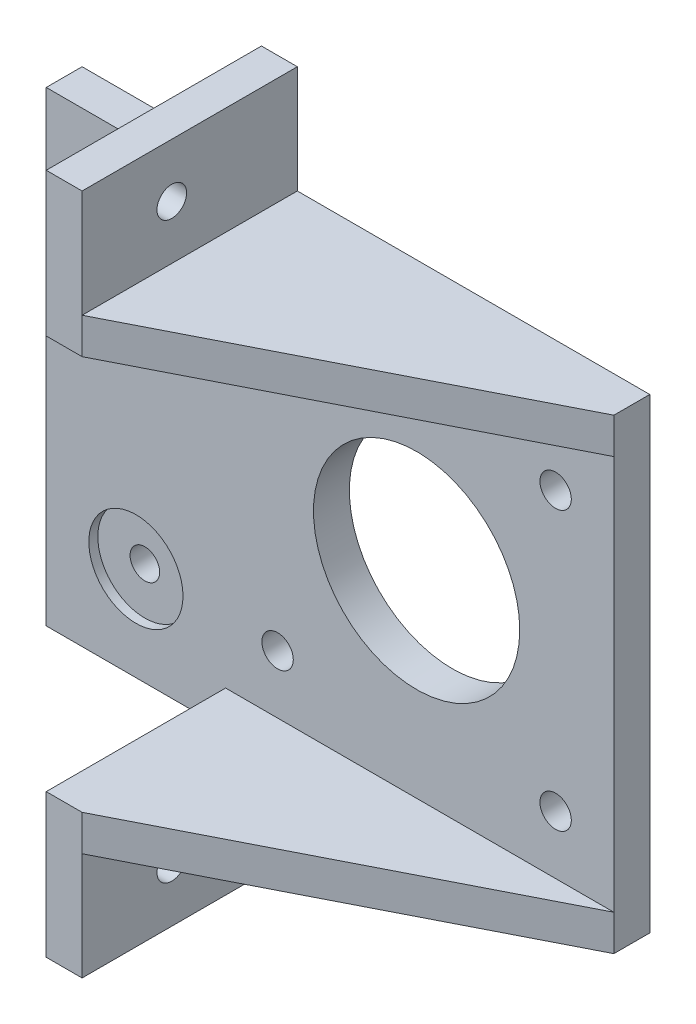
from build123d import *

# Parameters (mm, degrees)
ESBO_O1_W                  = 63.3
ESBO_O1_H                  = 52
ESBO_O1_R                  = 11.5
ESBO_O1_R_2                = 1.75
ESBO_O1_R_3                = 1.65
RESSALTO_EXTRUS_O1_DEPTH   = 25
ESBO_O2_W                  = 13.3
ESBO_O2_H                  = 21
CORTE_EXTRUS_O1_DEPTH      = 27
CORTE_EXTRUS_O1_DEPTH_BACK = 27
RESSALTO_EXTRUS_O2_DEPTH   = 4
ESBO_O4_W                  = 24
ESBO_O4_H                  = 16
ESBO_O4_R                  = 1.65
RESSALTO_EXTRUS_O3_DEPTH   = 4
ESBO_O5_R                  = 5.25
CORTE_EXTRUS_O2_DEPTH      = 1
ESBO_O6_R                  = 5.25
CORTE_EXTRUS_O3_DEPTH      = 1


with BuildPart() as part:
    # Esboço1 → Ressalto-extrusão1 (new body)
    with BuildSketch(Plane.XY):
        with Locations((-9.65, 0)):
            Rectangle(ESBO_O1_W, ESBO_O1_H)
        Circle(ESBO_O1_R, mode=Mode.SUBTRACT)
        with Locations((-15.5, 15.5)):
            Circle(ESBO_O1_R_2, mode=Mode.SUBTRACT)
        with Locations((15.5, 15.5)):
            Circle(ESBO_O1_R_2, mode=Mode.SUBTRACT)
        with Locations((15.5, -15.5)):
            Circle(ESBO_O1_R_2, mode=Mode.SUBTRACT)
        with Locations((-15.5, -15.5)):
            Circle(ESBO_O1_R_2, mode=Mode.SUBTRACT)
        with Locations((-31.3, -15.5)):
            Circle(ESBO_O1_R_3, mode=Mode.SUBTRACT)
        with Locations((-31.3, 15.5)):
            Circle(ESBO_O1_R_3, mode=Mode.SUBTRACT)
    extrude(amount=RESSALTO_EXTRUS_O1_DEPTH)

    # Esboço2 → Corte-extrusão1 (cut, two sides)
    with BuildSketch(Plane(origin=(0, 0, 0), x_dir=(1, 0, 0), z_dir=(0, 1, 0))) as corte_extrus_o1_sk:
        with Locations((-34.65, -14.5)):
            Rectangle(ESBO_O2_W, ESBO_O2_H)
        Polygon((-23, -25), (22, -25), (22, -4), align=None)
        Polygon((-23, -25), (22, -4), (-23, -4), (-28, -4), (-28, -25), align=None)
    extrude(amount=CORTE_EXTRUS_O1_DEPTH, mode=Mode.SUBTRACT)
    extrude(corte_extrus_o1_sk.sketch, amount=-CORTE_EXTRUS_O1_DEPTH_BACK, mode=Mode.SUBTRACT)

    # Esboço3 → Ressalto-extrusão2 (add)
    with BuildSketch(Plane(origin=(0, 26, 0), x_dir=(1, 0, 0), z_dir=(0, 1, 0))):
        Polygon((22, -4), (-17.3, -24), (-21.3, -24), (-21.3, -4), align=None)
    ressalto_extrus_o2 = extrude(amount=-RESSALTO_EXTRUS_O2_DEPTH)

    # Esboço4 → Ressalto-extrusão3 (add)
    with BuildSketch(Plane.ZY.offset(21.3)):
        with Locations((12, 30)):
            Rectangle(ESBO_O4_W, ESBO_O4_H)
        with Locations((14, 32)):
            Circle(ESBO_O4_R, mode=Mode.SUBTRACT)
    ressalto_extrus_o3 = extrude(amount=-RESSALTO_EXTRUS_O3_DEPTH)

    # Espelhar1: Ressalto-extrusão2, Ressalto-extrusão3 across plane
    add(ressalto_extrus_o2.mirror(Plane.ZX))
    add(ressalto_extrus_o3.mirror(Plane.ZX))

    # Esboço5 → Corte-extrusão2 (cut)
    with BuildSketch(Plane.ZY.offset(21.3)):
        with Locations((14, -32)):
            Circle(ESBO_O5_R)
        with Locations((14, 32)):
            Circle(ESBO_O5_R)
    extrude(amount=-CORTE_EXTRUS_O2_DEPTH, mode=Mode.SUBTRACT)

    # Esboço6 → Corte-extrusão3 (cut)
    with BuildSketch(Plane.XY.offset(4)):
        with Locations((-31.3, 15.5)):
            Circle(ESBO_O6_R)
        with Locations((-31.3, -15.5)):
            Circle(ESBO_O6_R)
    extrude(amount=-CORTE_EXTRUS_O3_DEPTH, mode=Mode.SUBTRACT)


solid = part.part
